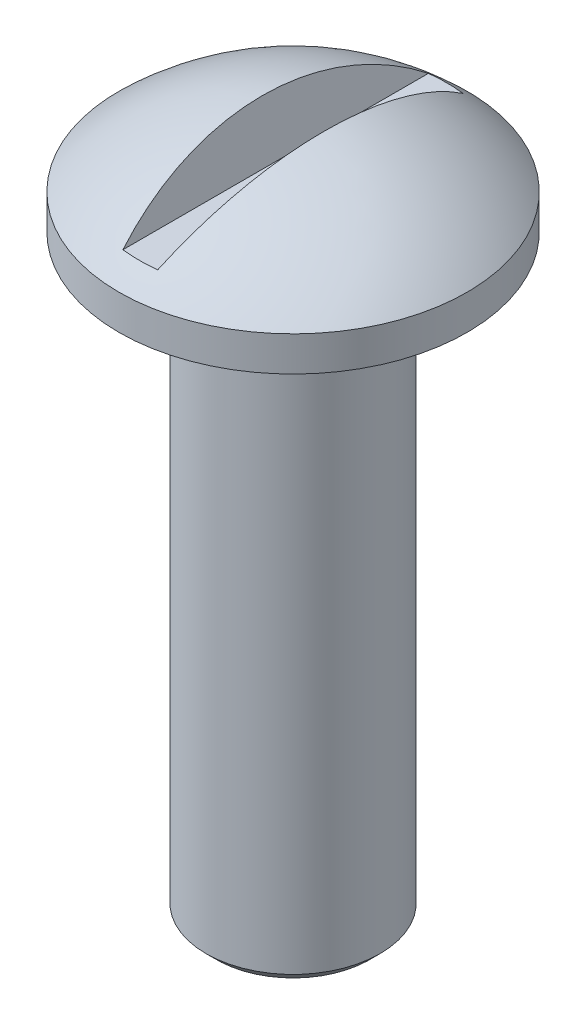
from build123d import *

# Parameters (mm, degrees)
DOME1_FACE_RADIUS       = 0.5
DOME1_HEIGHT            = 0.2
CUT_EXTRUDE1_DEPTH      = 1.5
CUT_EXTRUDE1_DEPTH_BACK = 1.5
CHAMFER1_SIZE           = 0.03


with BuildPart() as part:
    # Sketch2 → Revolve5 (revolve)
    with BuildSketch(Plane.XY):
        Polygon((0, 0), (-0.5, 0), (-0.5, -0.1), (-0.25, -0.1), (-0.25, -1.8), (0, -1.8), align=None)
    revolve(axis=Axis((0, 0.341610835, 0), (0, -1, 0)))

    # Dome1: a dome of height H over a round flat face of radius A is a cap of a sphere of radius (A * A + H * H) / (2 * H)
    dome1_r = (DOME1_FACE_RADIUS * DOME1_FACE_RADIUS + DOME1_HEIGHT * DOME1_HEIGHT) / (2 * DOME1_HEIGHT)
    dome1_base = Plane((0, 0, 0), z_dir=(0, 1, 0))
    with Locations(dome1_base.offset(DOME1_HEIGHT - dome1_r)):
        dome1_ball = Sphere(dome1_r, mode=Mode.PRIVATE)
    add(split(dome1_ball, bisect_by=dome1_base, keep=Keep.TOP, mode=Mode.PRIVATE))

    # Sketch3 → Cut-Extrude1 (cut, two sides)
    with BuildSketch(Plane.XY) as cut_extrude1_sk:
        Polygon((3.753414684, 13.871331761), (0.088731951, 0.19454961), (0.05, 0.05), (-0.05, 0.05), (-0.088731951, 0.19454961), (-3.753414684, 13.871331761), (-3.753414684, 42.189825332), (3.753414684, 42.189825332), align=None)
    extrude(amount=CUT_EXTRUDE1_DEPTH, mode=Mode.SUBTRACT)
    extrude(cut_extrude1_sk.sketch, amount=-CUT_EXTRUDE1_DEPTH_BACK, mode=Mode.SUBTRACT)

    # Chamfer1
    chamfer1_edges = [part.edges().sort_by_distance(p)[0] for p in [
        (0.25, -1.8, 0),
    ]]
    chamfer(chamfer1_edges, length=CHAMFER1_SIZE)


solid = part.part
